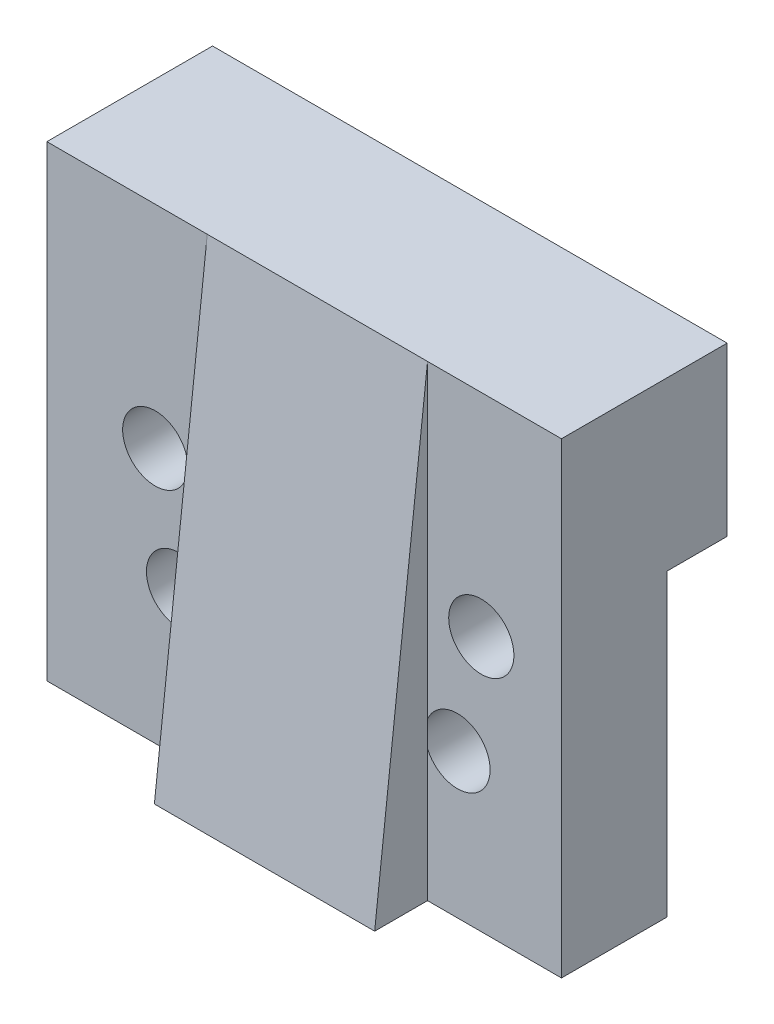
from build123d import *

# Parameters (mm, degrees)
SKETCH1_R           = 1
BOSS_EXTRUDE2_DEPTH = 1.7
SKETCH2_R           = 1.85
BOSS_EXTRUDE3_DEPTH = 4.3
BOSS_EXTRUDE4_DEPTH = 3.4
BOSS_EXTRUDE5_DEPTH = 12.5


with BuildPart() as part:
    # Sketch1 → Boss-Extrude2 (new body)
    with BuildSketch(Plane.XY):
        Polygon((-16.230109425, 8.75), (-16.230109425, -1.75), (-16.230109425, -7), (-16.230109425, -17.75), (12.969890575, -17.75), (12.969890575, -7), (12.969890575, -1.75), (12.969890575, 8.75), align=None)
        with Locations((-10.080109425, -3.25)):
            Circle(SKETCH1_R, mode=Mode.SUBTRACT)
        with Locations((8.419890575, -3.25)):
            Circle(SKETCH1_R, mode=Mode.SUBTRACT)
        with Locations((-8.730109425, -9.55)):
            Circle(SKETCH1_R, mode=Mode.SUBTRACT)
        with Locations((7.069890575, -9.55)):
            Circle(SKETCH1_R, mode=Mode.SUBTRACT)
    extrude(amount=BOSS_EXTRUDE2_DEPTH)

    # Sketch2 → Boss-Extrude3 (add)
    with BuildSketch(Plane.XY.offset(1.7)):
        Polygon((-16.230109425, 8.75), (-16.230109425, -1.75), (-16.230109425, -7), (-16.230109425, -17.75), (12.969890575, -17.75), (12.969890575, -7), (12.969890575, -1.75), (12.969890575, 8.75), align=None)
        with Locations((-10.080109425, -3.25)):
            Circle(SKETCH2_R, mode=Mode.SUBTRACT)
        with Locations((8.419890575, -3.25)):
            Circle(SKETCH2_R, mode=Mode.SUBTRACT)
        with Locations((-8.730109425, -9.55)):
            Circle(SKETCH2_R, mode=Mode.SUBTRACT)
        with Locations((7.069890575, -9.55)):
            Circle(SKETCH2_R, mode=Mode.SUBTRACT)
    extrude(amount=BOSS_EXTRUDE3_DEPTH)

    # Sketch3 → Boss-Extrude4 (add)
    with BuildSketch(Plane(origin=(0, 0, 0), x_dir=(-1, 0, 0), z_dir=(0, 0, -1))):
        Polygon((-3.869890575, -7), (5.530109425, -7), (7.030109425, -5.5), (7.030109425, -0.75), (16.230109425, -0.75), (16.230109425, 8.75), (-12.969890575, 8.75), (-12.969890575, -0.75), (-5.369890575, -0.75), (-5.369890575, -5.5), align=None)
    extrude(amount=BOSS_EXTRUDE4_DEPTH)

    # Sketch4 → Boss-Extrude5 (add)
    with BuildSketch(Plane(origin=(5.369890575, 0, 0), x_dir=(0, 0, -1), z_dir=(1, 0, 0))):
        Polygon((-6, -17.75), (-6, 8.75), (-9, -17.75), align=None)
    extrude(amount=-BOSS_EXTRUDE5_DEPTH)


solid = part.part
